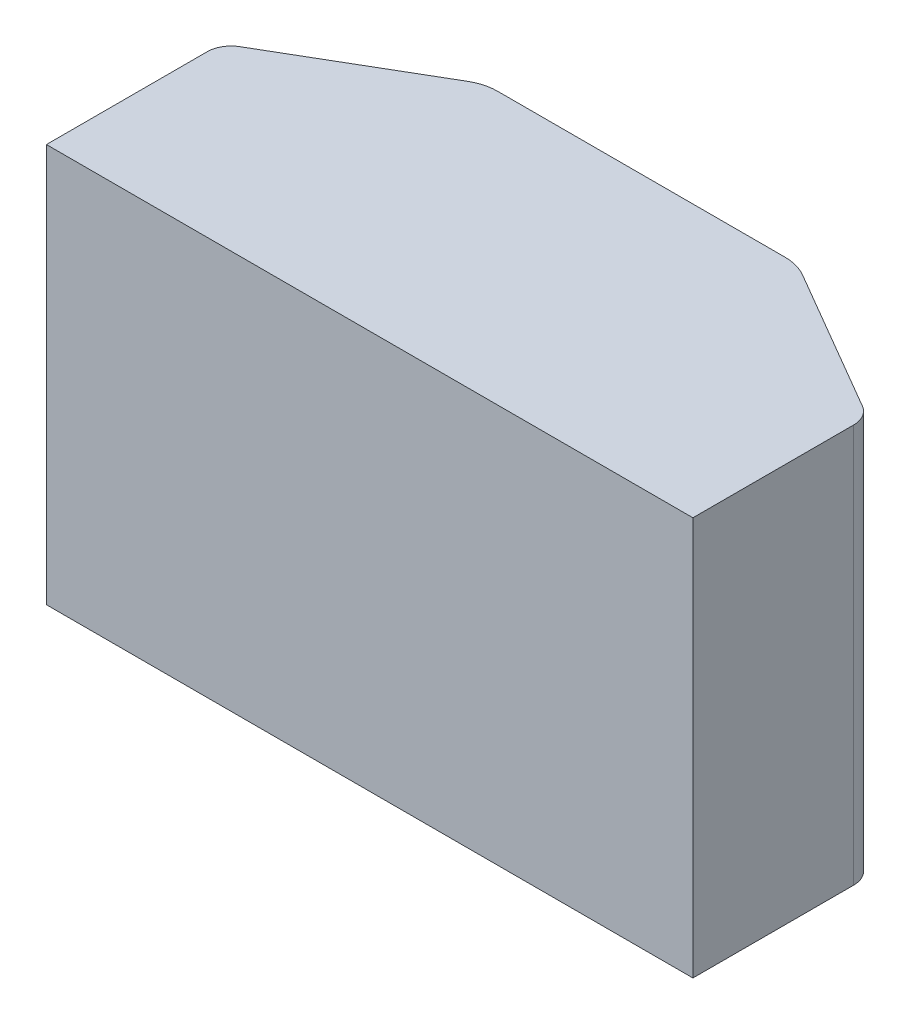
from build123d import *

# Parameters (mm, degrees)
SKETCH1_W           = 135.6
SKETCH1_H           = 83.6
BOSS_EXTRUDE1_DEPTH = 57
CUT_EXTRUDE2_DEPTH  = 84.6
FILLET2_R           = 10
FILLET3_R           = 5


with BuildPart() as part:
    # Sketch1 → Boss-Extrude1 (new body)
    with BuildSketch(Plane.XY):
        with Locations((67.8, -41.8)):
            Rectangle(SKETCH1_W, SKETCH1_H)
    extrude(amount=BOSS_EXTRUDE1_DEPTH)

    # Sketch3 → Cut-Extrude2 (cut, through all)
    with BuildSketch(Plane(origin=(0, 0, 0), x_dir=(1, 0, 0), z_dir=(0, 1, 0))):
        Polygon((100.6, 0), (135.6, 0), (135.6, -20.4), align=None)
        Polygon((35, 0), (0, 0), (0, -20.4), align=None)
    extrude(amount=-CUT_EXTRUDE2_DEPTH, mode=Mode.SUBTRACT)

    # Fillet2
    fillet2_edges = [part.edges().sort_by_distance(p)[0] for p in [
        (100.6, -41.8, 0),
        (35, -41.8, 0),
    ]]
    fillet(fillet2_edges, radius=FILLET2_R)

    # Fillet3
    fillet3_edges = [part.edges().sort_by_distance(p)[0] for p in [
        (135.6, -41.8, 20.4),
        (0, -41.8, 20.4),
    ]]
    fillet(fillet3_edges, radius=FILLET3_R)


solid = part.part
